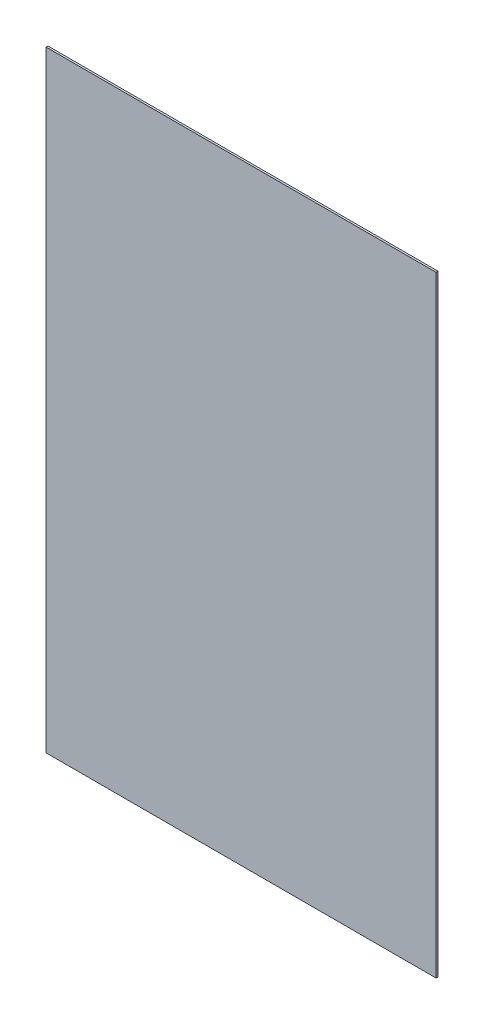
from build123d import *

# Parameters (mm, degrees)
SKETCH1_W           = 1000
SKETCH1_H           = 1567.75
BOSS_EXTRUDE1_DEPTH = 2.5


with BuildPart() as part:
    # Sketch1 → Boss-Extrude1 (new body, symmetric)
    with BuildSketch(Plane.XY):
        Rectangle(SKETCH1_W, SKETCH1_H)
    extrude(amount=BOSS_EXTRUDE1_DEPTH, both=True)


solid = part.part
